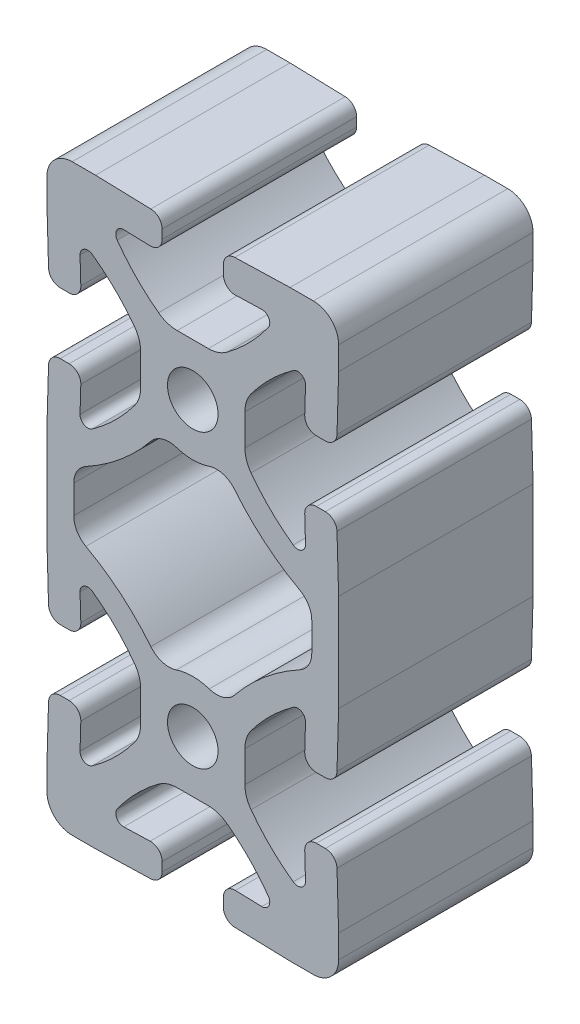
from build123d import *

# Parameters (mm, degrees)
SKETCH1_R      = 3.302
EXTRUDE1_DEPTH = 25.4


with BuildPart() as part:
    # Sketch1 → Extrude1 (new body)
    with BuildSketch(Plane.XY):
        with BuildLine():
            Line((-19.05, 16.002), (-19.05, 12.7))
            Line((-19.05, 12.7), (-18.83919774, 5.480022603))
            ThreePointArc((-18.83919774, 5.480022603), (-18.377636069, 4.43125722), (-17.315846907, 4.0005))
            Line((-17.315846907, 4.0005), (-16.146949, 4.0005))
            ThreePointArc((-16.146949, 4.0005), (-15.05370622, 4.462710838), (-14.623598167, 5.568977397))
            Line((-14.623598167, 5.568977397), (-14.724149279, 9.012852984))
            ThreePointArc((-14.724149279, 9.012852984), (-14.186349682, 9.93916176), (-13.117546632, 9.868902262))
            ThreePointArc((-13.117546632, 9.868902262), (-10.155121905, 7.382267737), (-7.611817848, 4.4683501))
            ThreePointArc((-7.611817848, 4.4683501), (-7.013595493, 3.319562661), (-6.8072, 2.04089794))
            Line((-6.8072, 2.04089794), (-6.8072, -2.04089794))
            ThreePointArc((-6.8072, -2.04089794), (-7.013595493, -3.319562661), (-7.611817848, -4.4683501))
            ThreePointArc((-7.611817848, -4.4683501), (-10.155121905, -7.382267737), (-13.117546632, -9.868902262))
            ThreePointArc((-13.117546632, -9.868902262), (-14.186349682, -9.93916176), (-14.724149279, -9.012852984))
            Line((-14.724149279, -9.012852984), (-14.623598167, -5.568977397))
            ThreePointArc((-14.623598167, -5.568977397), (-15.05370622, -4.462710838), (-16.146949, -4.0005))
            Line((-16.146949, -4.0005), (-17.315846907, -4.0005))
            ThreePointArc((-17.315846907, -4.0005), (-18.377636069, -4.43125722), (-18.83919774, -5.480022603))
            Line((-18.83919774, -5.480022603), (-19.05, -12.7))
            Line((-19.05, -12.7), (-19.05, -15.748))
            ThreePointArc((-19.05, -15.748), (-18.082866591, -18.082866591), (-15.748, -19.05))
            Line((-15.748, -19.05), (-12.7, -19.05))
            Line((-12.7, -19.05), (-5.480022603, -18.83919774))
            ThreePointArc((-5.480022603, -18.83919774), (-4.43125722, -18.377636069), (-4.0005, -17.315846907))
            Line((-4.0005, -17.315846907), (-4.0005, -16.146949))
            ThreePointArc((-4.0005, -16.146949), (-4.462710838, -15.05370622), (-5.568977397, -14.623598167))
            Line((-5.568977397, -14.623598167), (-9.012852984, -14.724149279))
            ThreePointArc((-9.012852984, -14.724149279), (-9.93916176, -14.186349682), (-9.868902262, -13.117546632))
            ThreePointArc((-9.868902262, -13.117546632), (-7.382267737, -10.155121905), (-4.4683501, -7.611817848))
            ThreePointArc((-4.4683501, -7.611817848), (-3.319562661, -7.013595493), (-2.04089794, -6.8072))
            Line((-2.04089794, -6.8072), (2.04089794, -6.8072))
            ThreePointArc((2.04089794, -6.8072), (3.319562661, -7.013595493), (4.4683501, -7.611817848))
            ThreePointArc((4.4683501, -7.611817848), (7.382267737, -10.155121905), (9.868902262, -13.117546632))
            ThreePointArc((9.868902262, -13.117546632), (9.93916176, -14.186349682), (9.012852984, -14.724149279))
            Line((9.012852984, -14.724149279), (5.568977397, -14.623598167))
            ThreePointArc((5.568977397, -14.623598167), (4.462710838, -15.05370622), (4.0005, -16.146949))
            Line((4.0005, -16.146949), (4.0005, -17.315846907))
            ThreePointArc((4.0005, -17.315846907), (4.43125722, -18.377636069), (5.480022603, -18.83919774))
            Line((5.480022603, -18.83919774), (12.7, -19.05))
            Line((12.7, -19.05), (15.748, -19.05))
            ThreePointArc((15.748, -19.05), (18.082866591, -18.082866591), (19.05, -15.748))
            Line((19.05, -15.748), (19.05, -12.7))
            Line((19.05, -12.7), (18.83919774, -5.480022603))
            ThreePointArc((18.83919774, -5.480022603), (18.377636069, -4.43125722), (17.315846907, -4.0005))
            Line((17.315846907, -4.0005), (16.146949, -4.0005))
            ThreePointArc((16.146949, -4.0005), (15.05370622, -4.462710838), (14.623598167, -5.568977397))
            Line((14.623598167, -5.568977397), (14.724149279, -9.012852984))
            ThreePointArc((14.724149279, -9.012852984), (14.186349682, -9.93916176), (13.117546632, -9.868902262))
            ThreePointArc((13.117546632, -9.868902262), (10.155121905, -7.382267737), (7.611817848, -4.4683501))
            ThreePointArc((7.611817848, -4.4683501), (7.013595493, -3.319562661), (6.8072, -2.04089794))
            Line((6.8072, -2.04089794), (6.8072, 2.04089794))
            ThreePointArc((6.8072, 2.04089794), (7.013595493, 3.319562661), (7.611817848, 4.4683501))
            ThreePointArc((7.611817848, 4.4683501), (10.155121905, 7.382267737), (13.117546632, 9.868902262))
            ThreePointArc((13.117546632, 9.868902262), (14.186349682, 9.93916176), (14.724149279, 9.012852984))
            Line((14.724149279, 9.012852984), (14.623598167, 5.568977397))
            ThreePointArc((14.623598167, 5.568977397), (15.05370622, 4.462710838), (16.146949, 4.0005))
            Line((16.146949, 4.0005), (17.315846907, 4.0005))
            ThreePointArc((17.315846907, 4.0005), (18.377636069, 4.43125722), (18.83919774, 5.480022603))
            Line((18.83919774, 5.480022603), (19.05, 12.7))
            Line((19.05, 12.7), (19.05, 16.032148553))
            Line((19.05, 16.032148553), (19.05, 22.067851447))
            Line((19.05, 22.067851447), (19.05, 25.4))
            Line((19.05, 25.4), (18.83919774, 32.619977397))
            ThreePointArc((18.83919774, 32.619977397), (18.377636069, 33.66874278), (17.315846907, 34.0995))
            Line((17.315846907, 34.0995), (16.146949, 34.0995))
            ThreePointArc((16.146949, 34.0995), (15.05370622, 33.637289162), (14.623598167, 32.531022603))
            Line((14.623598167, 32.531022603), (14.724149279, 29.087147016))
            ThreePointArc((14.724149279, 29.087147016), (14.186349682, 28.16083824), (13.117546632, 28.231097738))
            ThreePointArc((13.117546632, 28.231097738), (10.155121905, 30.717732263), (7.611817848, 33.6316499))
            ThreePointArc((7.611817848, 33.6316499), (7.013595493, 34.780437339), (6.8072, 36.05910206))
            Line((6.8072, 36.05910206), (6.8072, 38.1))
            Line((6.8072, 38.1), (6.8072, 40.14089794))
            ThreePointArc((6.8072, 40.14089794), (7.013595493, 41.419562661), (7.611817848, 42.5683501))
            ThreePointArc((7.611817848, 42.5683501), (10.155121905, 45.482267737), (13.117546632, 47.968902262))
            ThreePointArc((13.117546632, 47.968902262), (14.186349682, 48.03916176), (14.724149279, 47.112852984))
            Line((14.724149279, 47.112852984), (14.623598167, 43.668977397))
            ThreePointArc((14.623598167, 43.668977397), (15.05370622, 42.562710838), (16.146949, 42.1005))
            Line((16.146949, 42.1005), (17.315846907, 42.1005))
            ThreePointArc((17.315846907, 42.1005), (18.377636069, 42.53125722), (18.83919774, 43.580022603))
            Line((18.83919774, 43.580022603), (19.05, 50.8))
            Line((19.05, 50.8), (19.05, 53.848))
            ThreePointArc((19.05, 53.848), (18.082866591, 56.182866591), (15.748, 57.15))
            Line((15.748, 57.15), (12.7, 57.15))
            Line((12.7, 57.15), (5.480022603, 56.93919774))
            ThreePointArc((5.480022603, 56.93919774), (4.43125722, 56.477636069), (4.0005, 55.415846907))
            Line((4.0005, 55.415846907), (4.0005, 54.246949))
            ThreePointArc((4.0005, 54.246949), (4.462710838, 53.15370622), (5.568977397, 52.723598167))
            Line((5.568977397, 52.723598167), (9.012852984, 52.824149279))
            ThreePointArc((9.012852984, 52.824149279), (9.93916176, 52.286349682), (9.868902262, 51.217546632))
            ThreePointArc((9.868902262, 51.217546632), (7.382267737, 48.255121905), (4.4683501, 45.711817848))
            ThreePointArc((4.4683501, 45.711817848), (3.319562661, 45.113595493), (2.04089794, 44.9072))
            Line((2.04089794, 44.9072), (-2.04089794, 44.9072))
            ThreePointArc((-2.04089794, 44.9072), (-3.319562661, 45.113595493), (-4.4683501, 45.711817848))
            ThreePointArc((-4.4683501, 45.711817848), (-7.382267737, 48.255121905), (-9.868902262, 51.217546632))
            ThreePointArc((-9.868902262, 51.217546632), (-9.93916176, 52.286349682), (-9.012852984, 52.824149279))
            Line((-9.012852984, 52.824149279), (-5.568977397, 52.723598167))
            ThreePointArc((-5.568977397, 52.723598167), (-4.462710838, 53.15370622), (-4.0005, 54.246949))
            Line((-4.0005, 54.246949), (-4.0005, 55.415846907))
            ThreePointArc((-4.0005, 55.415846907), (-4.43125722, 56.477636069), (-5.480022603, 56.93919774))
            Line((-5.480022603, 56.93919774), (-12.7, 57.15))
            Line((-12.7, 57.15), (-15.748, 57.15))
            ThreePointArc((-15.748, 57.15), (-18.082866591, 56.182866591), (-19.05, 53.848))
            Line((-19.05, 53.848), (-19.05, 50.8))
            Line((-19.05, 50.8), (-18.83919774, 43.580022603))
            ThreePointArc((-18.83919774, 43.580022603), (-18.377636069, 42.53125722), (-17.315846907, 42.1005))
            Line((-17.315846907, 42.1005), (-16.146949, 42.1005))
            ThreePointArc((-16.146949, 42.1005), (-15.05370622, 42.562710838), (-14.623598167, 43.668977397))
            Line((-14.623598167, 43.668977397), (-14.724149279, 47.112852984))
            ThreePointArc((-14.724149279, 47.112852984), (-14.186349682, 48.03916176), (-13.117546632, 47.968902262))
            ThreePointArc((-13.117546632, 47.968902262), (-10.155121905, 45.482267737), (-7.611817848, 42.5683501))
            ThreePointArc((-7.611817848, 42.5683501), (-7.013595493, 41.419562661), (-6.8072, 40.14089794))
            Line((-6.8072, 40.14089794), (-6.8072, 38.1))
            Line((-6.8072, 38.1), (-6.8072, 36.05910206))
            ThreePointArc((-6.8072, 36.05910206), (-7.013595493, 34.780437339), (-7.611817848, 33.6316499))
            ThreePointArc((-7.611817848, 33.6316499), (-10.155121905, 30.717732263), (-13.117546632, 28.231097738))
            ThreePointArc((-13.117546632, 28.231097738), (-14.186349682, 28.16083824), (-14.724149279, 29.087147016))
            Line((-14.724149279, 29.087147016), (-14.623598167, 32.531022603))
            ThreePointArc((-14.623598167, 32.531022603), (-15.05370622, 33.637289162), (-16.146949, 34.0995))
            Line((-16.146949, 34.0995), (-17.315846907, 34.0995))
            ThreePointArc((-17.315846907, 34.0995), (-18.377636069, 33.66874278), (-18.83919774, 32.619977397))
            Line((-18.83919774, 32.619977397), (-19.05, 25.4))
            Line((-19.05, 25.4), (-19.05, 22.098))
            Line((-19.05, 22.098), (-19.05, 16.002))
        make_face()
        Circle(SKETCH1_R, mode=Mode.SUBTRACT)
        with BuildLine():
            Line((-15.5448, 17.204811254), (-15.5448, 20.895188746))
            ThreePointArc((-15.5448, 20.895188746), (-15.119287213, 22.448528636), (-13.96155537, 23.568163812))
            ThreePointArc((-13.96155537, 23.568163812), (-9.373378669, 26.699782358), (-5.479878947, 30.661986299))
            ThreePointArc((-5.479878947, 30.661986299), (-3.966302056, 31.672364112), (-2.146757643, 31.640170013))
            ThreePointArc((-2.146757643, 31.640170013), (0, 31.2928), (2.146757643, 31.640170013))
            ThreePointArc((2.146757643, 31.640170013), (3.966302056, 31.672364112), (5.479878947, 30.661986299))
            ThreePointArc((5.479878947, 30.661986299), (9.373378669, 26.699782358), (13.96155537, 23.568163812))
            ThreePointArc((13.96155537, 23.568163812), (15.119287213, 22.448528636), (15.5448, 20.895188746))
            Line((15.5448, 20.895188746), (15.5448, 17.204811254))
            ThreePointArc((15.5448, 17.204811254), (15.119287213, 15.651471364), (13.96155537, 14.531836188))
            ThreePointArc((13.96155537, 14.531836188), (9.373378669, 11.400217642), (5.479878947, 7.438013701))
            ThreePointArc((5.479878947, 7.438013701), (3.966302056, 6.427635888), (2.146757643, 6.459829987))
            ThreePointArc((2.146757643, 6.459829987), (0, 6.8072), (-2.146757643, 6.459829987))
            ThreePointArc((-2.146757643, 6.459829987), (-3.966302056, 6.427635888), (-5.479878947, 7.438013701))
            ThreePointArc((-5.479878947, 7.438013701), (-9.373378669, 11.400217642), (-13.96155537, 14.531836188))
            ThreePointArc((-13.96155537, 14.531836188), (-15.119287213, 15.651471364), (-15.5448, 17.204811254))
        make_face(mode=Mode.SUBTRACT)
        with Locations((0, 38.1)):
            Circle(SKETCH1_R, mode=Mode.SUBTRACT)
    extrude(amount=EXTRUDE1_DEPTH)


solid = part.part
